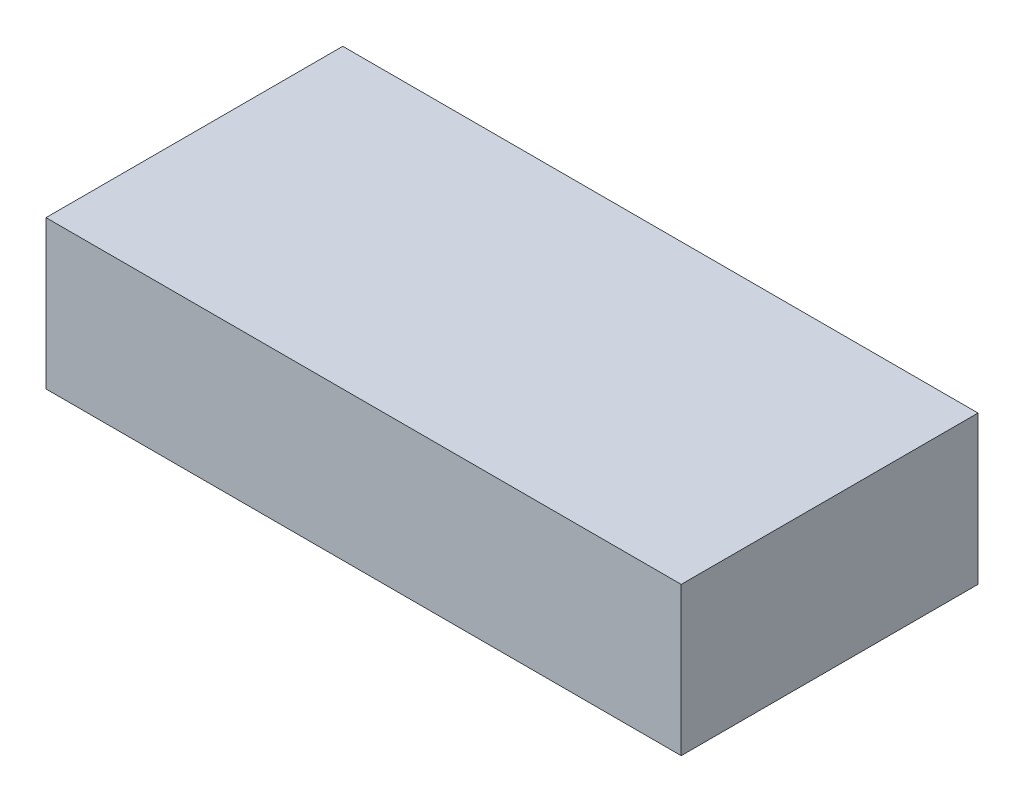
from build123d import *

# Parameters (mm, degrees)
CROQUIS1_W              = 488
CROQUIS1_H              = 228
SALIENTE_EXTRUIR1_DEPTH = 114


with BuildPart() as part:
    # Croquis1 → Saliente-Extruir1 (new body)
    with BuildSketch(Plane(origin=(0, 0, 0), x_dir=(1, 0, 0), z_dir=(0, 1, 0))):
        Rectangle(CROQUIS1_W, CROQUIS1_H)
    extrude(amount=SALIENTE_EXTRUIR1_DEPTH)


solid = part.part
